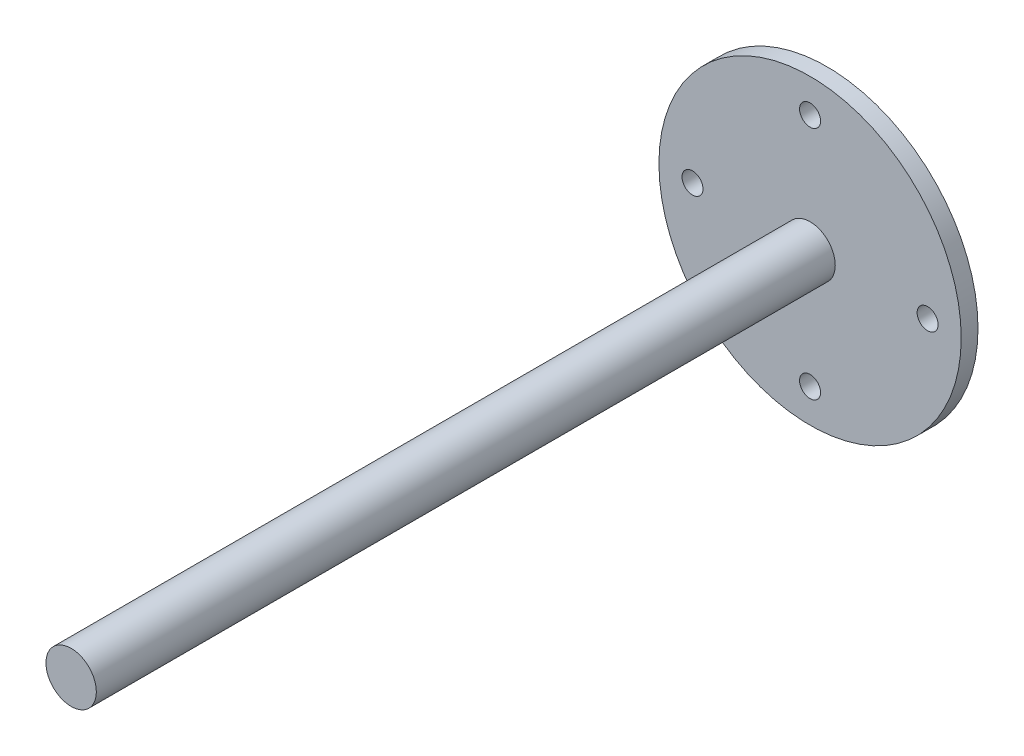
from build123d import *

# Parameters (mm, degrees)
SKETCH1_R           = 57.15
SKETCH1_R_2         = 3.96875
BOSS_EXTRUDE1_DEPTH = 6.35
SKETCH2_R           = 9.525
BOSS_EXTRUDE2_DEPTH = 279.4


with BuildPart() as part:
    # Sketch1 → Boss-Extrude1 (new body)
    with BuildSketch(Plane.XY):
        Circle(SKETCH1_R)
        with Locations((0, 44.45)):
            Circle(SKETCH1_R_2, mode=Mode.SUBTRACT)
        with Locations((44.45, 0)):
            Circle(SKETCH1_R_2, mode=Mode.SUBTRACT)
        with Locations((0, -44.45)):
            Circle(SKETCH1_R_2, mode=Mode.SUBTRACT)
        with Locations((-44.45, 0)):
            Circle(SKETCH1_R_2, mode=Mode.SUBTRACT)
    extrude(amount=BOSS_EXTRUDE1_DEPTH)

    # Sketch2 → Boss-Extrude2 (add)
    with BuildSketch(Plane.XY.offset(6.35)):
        Circle(SKETCH2_R)
    extrude(amount=BOSS_EXTRUDE2_DEPTH)


solid = part.part
